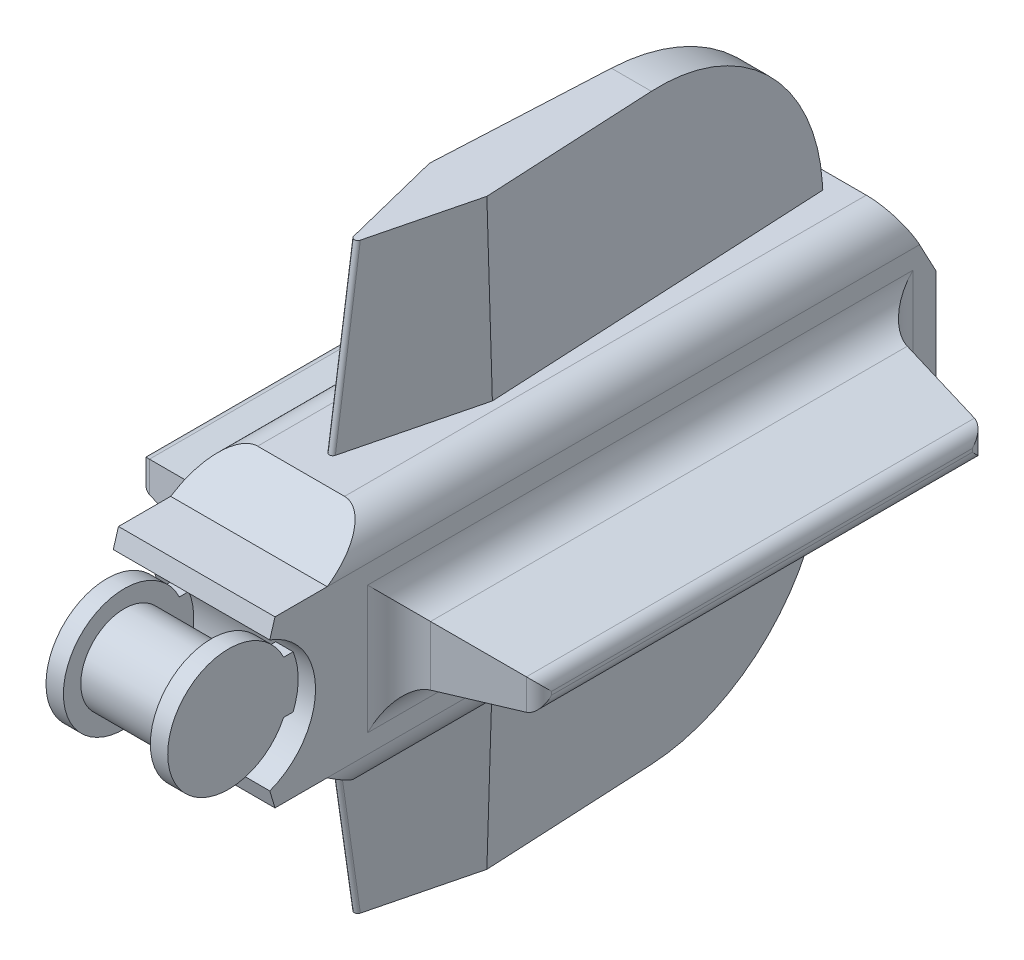
from build123d import *

# Parameters (mm, degrees)
SKETCH1_R                = 3.175
BOSS_EXTRUDE1_DEPTH      = 3.175
SKETCH2_R                = 4.445
BOSS_EXTRUDE2_DEPTH      = 1.27
SKETCH3_W                = 6.35
SKETCH3_H                = 3.81
BOSS_EXTRUDE3_DEPTH      = 1.27
BOSS_EXTRUDE4_DEPTH      = 8.89
BOSS_EXTRUDE4_DEPTH_BACK = 2.54
SKETCH5_R                = 3.175
CUT_EXTRUDE1_DEPTH       = 12.7
FILLET1_R                = 2.54
SKETCH6_W                = 35.56
SKETCH6_H                = 5.08
BOSS_EXTRUDE5_DEPTH      = 8.89
BOSS_EXTRUDE5_TAPER      = 10
FILLET2_R                = 1.016
FILLET3_R                = 2.54
BOSS_EXTRUDE6_DEPTH      = 12.7
BOSS_EXTRUDE6_TAPER      = 2
FILLET4_R                = 0.254
FILLET5_R                = 12.7


with BuildPart() as part:
    # Sketch1 → Boss-Extrude1 (new body, symmetric)
    with BuildSketch(Plane(origin=(0, 0, 0), x_dir=(0, 0, -1), z_dir=(1, 0, 0))):
        Circle(SKETCH1_R)
    extrude(amount=BOSS_EXTRUDE1_DEPTH, both=True)

    # Sketch2 → Boss-Extrude2 (add)
    with BuildSketch(Plane(origin=(3.175, 0, 0), x_dir=(0, 0, -1), z_dir=(1, 0, 0))):
        Circle(SKETCH2_R)
    boss_extrude2 = extrude(amount=BOSS_EXTRUDE2_DEPTH)

    # Mirror1: Boss-Extrude2 across plane
    add(boss_extrude2.mirror(Plane(origin=(0, 0, 0), x_dir=(0, 0, 1), z_dir=(1, 0, 0))))

    # Sketch3 → Boss-Extrude3 (add)
    with BuildSketch(Plane(origin=(4.445, 0, 0), x_dir=(0, 0, -1), z_dir=(1, 0, 0))):
        with Locations((3.175, 0)):
            Rectangle(SKETCH3_W, SKETCH3_H)
    boss_extrude3 = extrude(amount=-BOSS_EXTRUDE3_DEPTH)

    # Mirror2: Boss-Extrude3 across plane
    add(boss_extrude3.mirror(Plane(origin=(0, 0, 0), x_dir=(0, 0, 1), z_dir=(1, 0, 0))))

    # Sketch4 → Boss-Extrude4 (add, two sides)
    with BuildSketch(Plane(origin=(-3.175, 0, 0), x_dir=(0, 0, -1), z_dir=(1, 0, 0))) as boss_extrude4_sk:
        with BuildLine():
            Line((1.737462328, 4.773638514), (2.118462328, 6.043638514))
            Line((2.118462328, 6.043638514), (5.928462328, 6.043638514))
            Line((5.928462328, 6.043638514), (9.738462328, 8.583638514))
            Line((9.738462328, 8.583638514), (47.838462328, 8.583638514))
            Line((47.838462328, 8.583638514), (50.378462328, 3.81))
            Line((50.378462328, 3.81), (50.378462328, -3.81))
            Line((50.378462328, -3.81), (47.838462328, -8.583638514))
            Line((47.838462328, -8.583638514), (9.738462328, -8.583638514))
            Line((9.738462328, -8.583638514), (5.928462328, -6.043638514))
            Line((5.928462328, -6.043638514), (2.118462328, -6.043638514))
            Line((2.118462328, -6.043638514), (1.737462328, -4.773638514))
            ThreePointArc((1.737462328, -4.773638514), (5.08, 0), (1.737462328, 4.773638514))
        make_face()
    extrude(amount=BOSS_EXTRUDE4_DEPTH)
    extrude(boss_extrude4_sk.sketch, amount=-BOSS_EXTRUDE4_DEPTH_BACK)

    # Sketch5 → Cut-Extrude1 (cut)
    with BuildSketch(Plane(origin=(0, 0, -50.378462328), x_dir=(-1, 0, 0), z_dir=(0, 0, -1))):
        Circle(SKETCH5_R)
    extrude(amount=-CUT_EXTRUDE1_DEPTH, mode=Mode.SUBTRACT)

    # Fillet1
    fillet1_edges = [part.edges().sort_by_distance(p)[0] for p in [
        (5.715, -8.583638514, -28.788462328),
        (-5.715, -8.583638514, -28.788462328),
        (-5.715, 8.583638514, -28.788462328),
        (5.715, 8.583638514, -28.788462328),
    ]]
    fillet(fillet1_edges, radius=FILLET1_R)

    # Sketch6 → Boss-Extrude5 (add)
    with BuildSketch(Plane(origin=(5.715, 0, 0), x_dir=(0, 0, -1), z_dir=(1, 0, 0))):
        with Locations((28.788462328, 0)):
            Rectangle(SKETCH6_W, SKETCH6_H)
    boss_extrude5 = extrude(amount=BOSS_EXTRUDE5_DEPTH, taper=BOSS_EXTRUDE5_TAPER)

    # Mirror3: Boss-Extrude5 across plane
    add(boss_extrude5.mirror(Plane(origin=(0, 0, 0), x_dir=(0, 0, 1), z_dir=(1, 0, 0))))

    # Fillet2
    fillet2_edges = [part.edges().sort_by_distance(p)[0] for p in [
        (14.605, 0, -12.576009187),
        (14.605, -0.972453142, -28.788462328),
        (14.605, 0, -45.00091547),
        (14.605, 0.972453142, -28.788462328),
        (-14.605, 0, -12.576009187),
        (-14.605, 0.972453142, -28.788462328),
        (-14.605, 0, -45.00091547),
        (-14.605, -0.972453142, -28.788462328),
    ]]
    fillet(fillet2_edges, radius=FILLET2_R)

    # Fillet3
    fillet3_edges = [part.edges().sort_by_distance(p)[0] for p in [
        (5.715, 0, -11.008462328),
        (5.715, -2.54, -28.788462328),
        (5.715, 0, -46.568462328),
        (5.715, 2.54, -28.788462328),
        (-5.715, 0, -11.008462328),
        (-5.715, -2.54, -28.788462328),
        (-5.715, 0, -46.568462328),
        (-5.715, 2.54, -28.788462328),
    ]]
    fillet(fillet3_edges, radius=FILLET3_R)

    # Sketch7 → Boss-Extrude6 (add)
    with BuildSketch(Plane(origin=(0, 8.583638514, 0), x_dir=(1, 0, 0), z_dir=(0, 1, 0))):
        Polygon((-1.27, 46.568462328), (-2.54, 21.168462328), (0, 11.008462328), (2.54, 21.168462328), (1.27, 46.568462328), align=None)
    boss_extrude6 = extrude(amount=BOSS_EXTRUDE6_DEPTH, taper=BOSS_EXTRUDE6_TAPER)

    # Mirror4: Boss-Extrude6 across plane
    add(boss_extrude6.mirror(Plane.ZX))

    # Fillet4
    fillet4_edges = [part.edges().sort_by_distance(p)[0] for p in [
        (0, 14.933638514, -11.922748162),
        (0, -14.933638514, -11.922748162),
    ]]
    fillet(fillet4_edges, radius=FILLET4_R)

    # Fillet5
    fillet5_edges = [part.edges().sort_by_distance(p)[0] for p in [
        (0, 21.283638514, -46.124968556),
        (0, -21.283638514, -46.124968556),
    ]]
    fillet(fillet5_edges, radius=FILLET5_R)


solid = part.part
